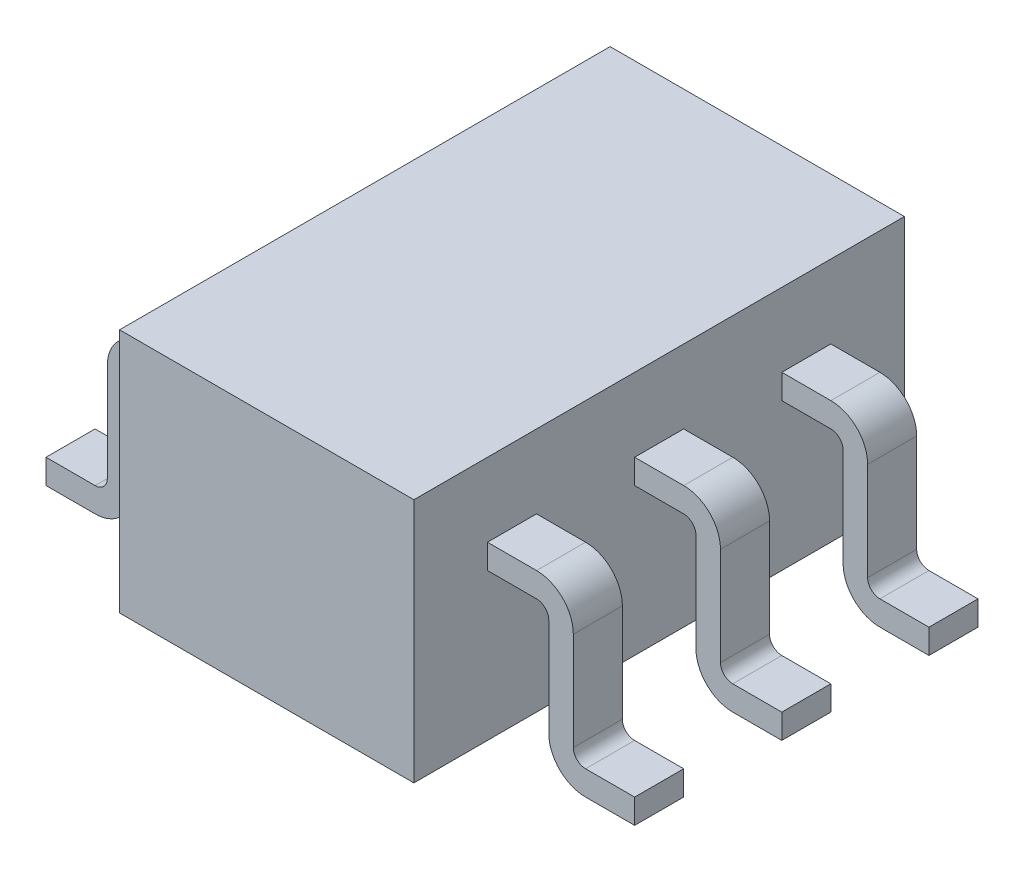
from build123d import *

# Parameters (mm, degrees)
BASES_W              = 1.2
BASES_H              = 2
BASE_DEPTH           = 0.5
MIDDLELEG_DEPTH      = 0.1
LPATTERN1_COUNT      = 3
LPATTERN1_PITCH      = 0.6
MIRROR1_COPY_1_DEPTH = 0.1
MIRROR1_COPY_2_DEPTH = 0.1


with BuildPart() as part:
    # BaseS → Base (new body, symmetric)
    with BuildSketch(Plane(origin=(0, 0, 0), x_dir=(1, 0, 0), z_dir=(0, 1, 0))):
        Rectangle(BASES_W, BASES_H)
    extrude(amount=BASE_DEPTH, both=True)

    # MiddleLegS → MiddleLeg (add, symmetric)
    with BuildSketch(Plane.XY.offset(0.6)):
        with BuildLine():
            Line((1.2, -0.4), (1, -0.4))
            ThreePointArc((1, -0.4), (0.964644661, -0.385355339), (0.95, -0.35))
            Line((0.95, -0.35), (0.95, 0.05))
            ThreePointArc((0.95, 0.05), (0.906066017, 0.156066017), (0.8, 0.2))
            Line((0.8, 0.2), (0.6, 0.2))
            Line((0.6, 0.2), (0.6, 0.1))
            Line((0.6, 0.1), (0.8, 0.1))
            ThreePointArc((0.8, 0.1), (0.835355339, 0.085355339), (0.85, 0.05))
            Line((0.85, 0.05), (0.85, -0.35))
            ThreePointArc((0.85, -0.35), (0.893933983, -0.456066017), (1, -0.5))
            Line((1, -0.5), (1.2, -0.5))
            Line((1.2, -0.5), (1.2, -0.4))
        make_face()
    middleleg = extrude(amount=MIDDLELEG_DEPTH, both=True)

    # LPattern1: MiddleLeg ×3
    with Locations(*[(0, 0, -i * LPATTERN1_PITCH) for i in range(1, LPATTERN1_COUNT)]):
        add(middleleg)

    # Mirror1: MiddleLeg across plane
    add(middleleg.mirror(Plane(origin=(0, 0, 0), x_dir=(0, 0, 1), z_dir=(1, 0, 0))))

    # Mirror1 copy 1 sketch → Mirror1 copy 1 (add, symmetric)
    with BuildSketch(Plane(origin=(0, 0, 0), x_dir=(-1, 0, 0), z_dir=(0, 0, 1))):
        with BuildLine():
            Line((1.2, 0.4), (1, 0.4))
            ThreePointArc((1, 0.4), (0.964644661, 0.385355339), (0.95, 0.35))
            Line((0.95, 0.35), (0.95, -0.05))
            ThreePointArc((0.95, -0.05), (0.906066017, -0.156066017), (0.8, -0.2))
            Line((0.8, -0.2), (0.6, -0.2))
            Line((0.6, -0.2), (0.6, -0.1))
            Line((0.6, -0.1), (0.8, -0.1))
            ThreePointArc((0.8, -0.1), (0.835355339, -0.085355339), (0.85, -0.05))
            Line((0.85, -0.05), (0.85, 0.35))
            ThreePointArc((0.85, 0.35), (0.893933983, 0.456066017), (1, 0.5))
            Line((1, 0.5), (1.2, 0.5))
            Line((1.2, 0.5), (1.2, 0.4))
        make_face()
    extrude(amount=MIRROR1_COPY_1_DEPTH, both=True)

    # Mirror1 copy 2 sketch → Mirror1 copy 2 (add, symmetric)
    with BuildSketch(Plane(origin=(0, 0, -0.6), x_dir=(-1, 0, 0), z_dir=(0, 0, 1))):
        with BuildLine():
            Line((1.2, 0.4), (1, 0.4))
            ThreePointArc((1, 0.4), (0.964644661, 0.385355339), (0.95, 0.35))
            Line((0.95, 0.35), (0.95, -0.05))
            ThreePointArc((0.95, -0.05), (0.906066017, -0.156066017), (0.8, -0.2))
            Line((0.8, -0.2), (0.6, -0.2))
            Line((0.6, -0.2), (0.6, -0.1))
            Line((0.6, -0.1), (0.8, -0.1))
            ThreePointArc((0.8, -0.1), (0.835355339, -0.085355339), (0.85, -0.05))
            Line((0.85, -0.05), (0.85, 0.35))
            ThreePointArc((0.85, 0.35), (0.893933983, 0.456066017), (1, 0.5))
            Line((1, 0.5), (1.2, 0.5))
            Line((1.2, 0.5), (1.2, 0.4))
        make_face()
    extrude(amount=MIRROR1_COPY_2_DEPTH, both=True)


solid = part.part
